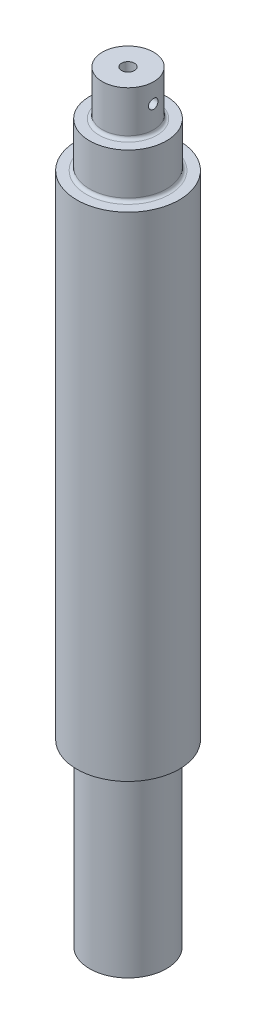
from build123d import *

# Parameters (mm, degrees)
SKETCH2_R          = 1.6002
CUT_EXTRUDE1_DEPTH = 12.7
SKETCH3_R          = 1.1811
CUT_EXTRUDE2_DEPTH = 12.7


with BuildPart() as part:
    # Sketch1 → Revolve1 (revolve)
    with BuildSketch(Plane.XY, mode=Mode.PRIVATE) as revolve1_sk:
        with BuildLine():
            Line((0, 83.34375), (-6.35, 83.34375))
            Line((-6.35, 83.34375), (-6.35, 73.025))
            ThreePointArc((-6.35, 73.025), (-6.582483992, 72.463733992), (-7.14375, 72.23125))
            Line((-7.14375, 72.23125), (-9.5377, 72.23125))
            Line((-9.5377, 72.23125), (-9.5377, 61.9125))
            ThreePointArc((-9.5377, 61.9125), (-9.770183992, 61.351233992), (-10.33145, 61.11875))
            Line((-10.33145, 61.11875), (-12.7, 61.11875))
            Line((-12.7, 61.11875), (-12.7, 0))
            Line((-12.7, 0), (-12.7, -61.11875))
            Line((-12.7, -61.11875), (-10.30605, -61.11875))
            ThreePointArc((-10.30605, -61.11875), (-9.744783992, -61.351233992), (-9.5123, -61.9125))
            Line((-9.5123, -61.9125), (-9.5123, -105.56875))
            Line((-9.5123, -105.56875), (0, -105.56875))
            Line((0, -105.56875), (0, 83.34375))
        make_face()
    revolve(revolve1_sk.sketch.rotate(Axis((0, -122.193490481, 0), (0, 1, 0)), 270), axis=Axis((0, -122.193490481, 0), (0, 1, 0)))

    # Sketch2 → Cut-Extrude1 (cut)
    with BuildSketch(Plane(origin=(0, 83.34375, 0), x_dir=(1, 0, 0), z_dir=(0, 1, 0))):
        with Locations(Location((0, 0, 0), (0, 0, 270))):
            Circle(SKETCH2_R)
    extrude(amount=-CUT_EXTRUDE1_DEPTH, mode=Mode.SUBTRACT)

    # Sketch3 → Cut-Extrude2 (cut, symmetric)
    with BuildSketch(Plane(origin=(0, 0, 0), x_dir=(0, 0, -1), z_dir=(1, 0, 0))):
        with Locations((0, 78.58125)):
            Circle(SKETCH3_R)
    extrude(amount=CUT_EXTRUDE2_DEPTH, both=True, mode=Mode.SUBTRACT)


solid = part.part
